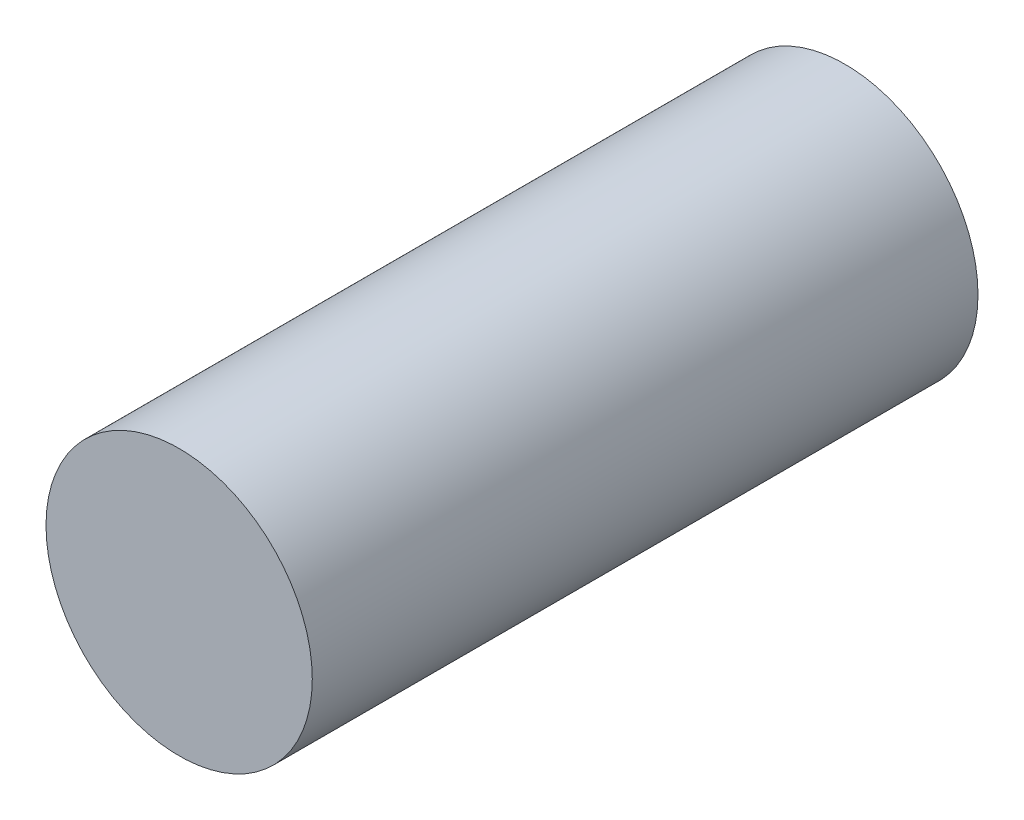
from build123d import *

# Parameters (mm, degrees)
SKETCH1_R           = 1
BOSS_EXTRUDE2_DEPTH = 5


with BuildPart() as part:
    # Sketch1 → Boss-Extrude2 (new body)
    with BuildSketch(Plane.XY):
        Circle(SKETCH1_R)
    extrude(amount=BOSS_EXTRUDE2_DEPTH)


solid = part.part
